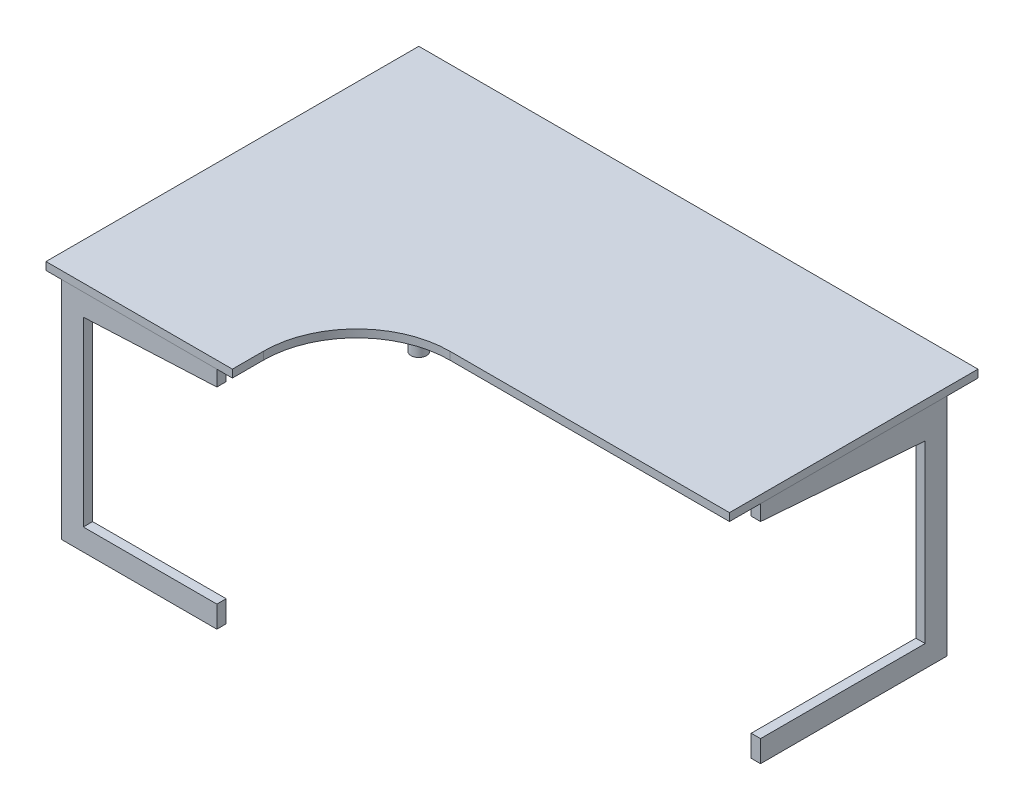
from build123d import *

# Parameters (mm, degrees)
EXTRUDE1_DEPTH = 30
EXTRUDE2_DEPTH = 25
EXTRUDE3_DEPTH = 30
SKETCH5_R      = 25
EXTRUDE4_DEPTH = 725


with BuildPart() as part:
    # Sketch1 → Extrude1 (new body)
    with BuildSketch(Plane(origin=(0, 0, 0), x_dir=(0, 0, -1), z_dir=(1, 0, 0))):
        Polygon((0, 0), (-600, 0), (-600, 70), (-70, 70), (-70, 635), (-600, 675), (-600, 725), (0, 725), align=None)
    extrude(amount=-EXTRUDE1_DEPTH)


with BuildPart() as body_2:
    # Sketch2 → Extrude2 (new body)
    with BuildSketch(Plane(origin=(0, 725, 0), x_dir=(-1, 0, 0), z_dir=(0, 1, 0))):
        with BuildLine():
            Line((0, 700), (900, 700))
            ThreePointArc((900, 700), (1112.132034356, 787.867965644), (1200, 1000))
            Line((1200, 1000), (1200, 1100))
            Line((1200, 1100), (1800, 1100))
            Line((1800, 1100), (1800, -100))
            Line((1800, -100), (0, -100))
            Line((0, -100), (0, 700))
        make_face()
    extrude(amount=EXTRUDE2_DEPTH)

    # Sketch5 → Extrude4 (add)
    with BuildSketch(Plane(origin=(0, 0, 0), x_dir=(1, 0, 0), z_dir=(0, 1, 0))):
        with Locations(Location((-1700, 0, 0), (0, 0, 270))):  # turned: the seam where the file's is
            Circle(SKETCH5_R)
    extrude(amount=EXTRUDE4_DEPTH)


with BuildPart() as body_3:
    # Sketch3 → Extrude3 (new body)
    with BuildSketch(Plane.XY.offset(1100)):
        Polygon((-1750, 725), (-1750, 0), (-1250, 0), (-1250, 70), (-1680, 70), (-1680, 655), (-1250, 675), (-1250, 725), align=None)
    extrude(amount=-EXTRUDE3_DEPTH)


solid = Compound([part.part, body_2.part, body_3.part])
